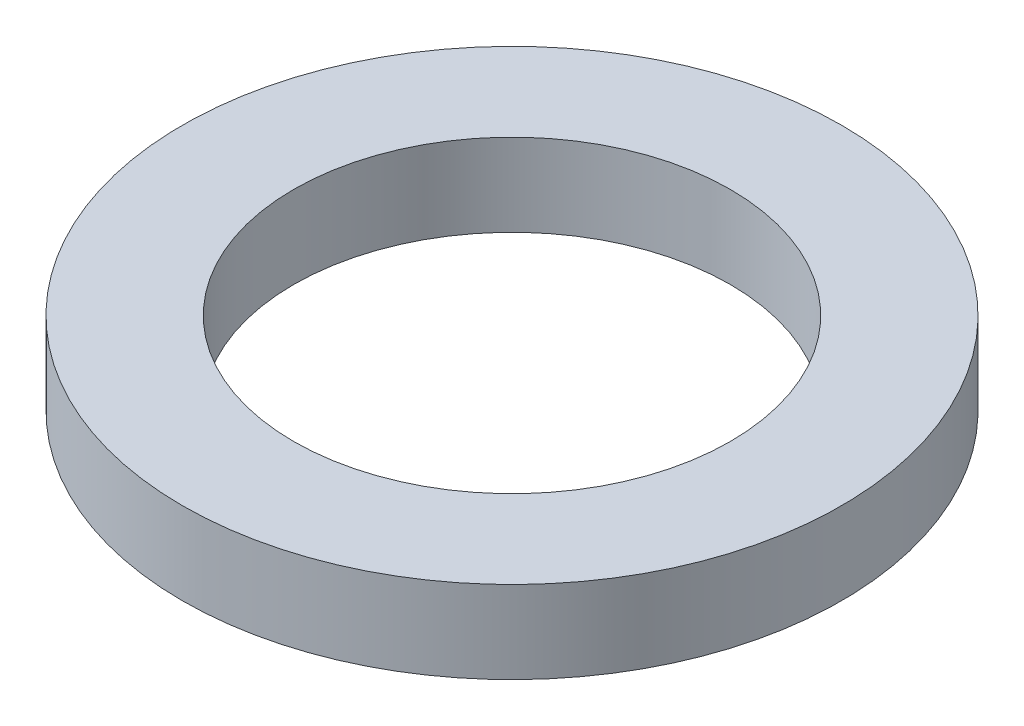
from build123d import *

# Parameters (mm, degrees)
SKETCH1_R           = 4
SKETCH1_R_2         = 2.65
BOSS_EXTRUDE1_DEPTH = 1


with BuildPart() as part:
    # Sketch1 → Boss-Extrude1 (new body)
    with BuildSketch(Plane(origin=(0, 0, 0), x_dir=(1, 0, 0), z_dir=(0, 1, 0))):
        Circle(SKETCH1_R)
        Circle(SKETCH1_R_2, mode=Mode.SUBTRACT)
    extrude(amount=BOSS_EXTRUDE1_DEPTH)


solid = part.part
